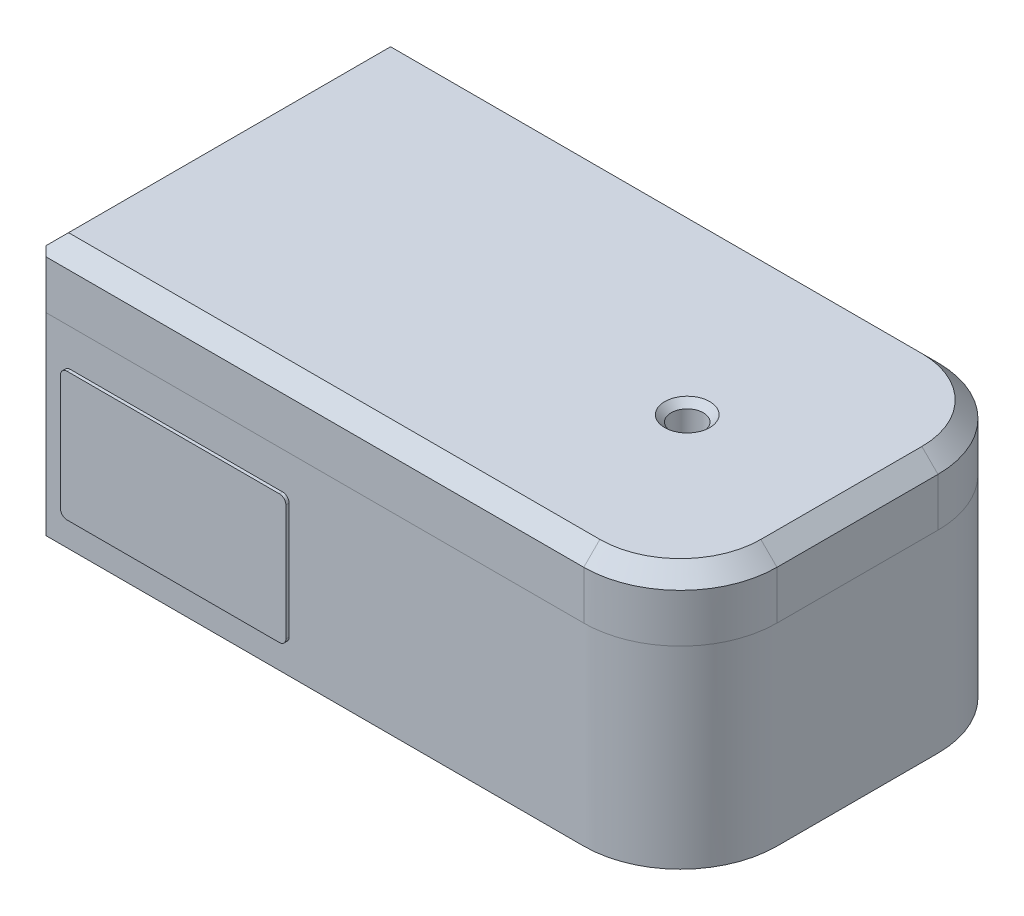
from build123d import *

# Parameters (mm, degrees)
SKETCH1_W           = 200
SKETCH1_H           = 110
BOSS_EXTRUDE1_DEPTH = 20
FILLET2_R           = 30
SKETCH2_R           = 5
CUT_EXTRUDE1_DEPTH  = 24
CHAMFER1_SIZE       = 5
BOSS_EXTRUDE2_DEPTH = 1
CUT_EXTRUDE2_DEPTH  = 5
CHAMFER2_SIZE       = 1
CHAMFER3_SIZE       = 2
CHAMFER4_SIZE       = 3


with BuildPart() as part:
    # Sketch1 → Boss-Extrude1 (new body)
    with BuildSketch(Plane(origin=(0, 0, 0), x_dir=(1, 0, 0), z_dir=(0, 1, 0))):
        with Locations((22.74566474, -0.63583815)):
            Rectangle(SKETCH1_W, SKETCH1_H)
    extrude(amount=BOSS_EXTRUDE1_DEPTH)

    # Fillet2
    fillet2_edges = [part.edges().sort_by_distance(p)[0] for p in [
        (122.74566474, 10, -54.36416185),
        (122.74566474, 10, 55.63583815),
    ]]
    fillet(fillet2_edges, radius=FILLET2_R)

    # Sketch4 → section 0 of loft1
    with BuildSketch(Plane(origin=(0, -60, 0), x_dir=(-1, 0, 0), z_dir=(0, -1, 0)), mode=Mode.PRIVATE) as loft1_s0:
        with BuildLine():
            Line((-122.74566474, 24.36416185), (-122.74566474, -25.63583815))
            ThreePointArc((-122.74566474, -25.63583815), (-113.958868175, -46.849041586), (-92.74566474, -55.63583815))
            Line((-92.74566474, -55.63583815), (77.25433526, -55.63583815))
            Line((77.25433526, -55.63583815), (77.25433526, 54.36416185))
            Line((77.25433526, 54.36416185), (-92.74566474, 54.36416185))
            ThreePointArc((-92.74566474, 54.36416185), (-113.958868175, 45.577365285), (-122.74566474, 24.36416185))
        make_face()
    # loft up to a face of the part (loft1)
    loft([loft1_s0.sketch, part.faces().sort_by_distance((21.078212912, 0, 0.63583815))[0]])

    # Sketch2 → Cut-Extrude1 (cut)
    with BuildSketch(Plane(origin=(0, 20, 0), x_dir=(1, 0, 0), z_dir=(0, 1, 0))):
        with Locations((72.74566474, -3.505923633)):
            Circle(SKETCH2_R)
    extrude(amount=-CUT_EXTRUDE1_DEPTH, mode=Mode.SUBTRACT)

    # Chamfer1
    chamfer1_edges = [part.edges().sort_by_distance(p)[0] for p in [
        (113.958868175, 20, 46.849041586),
        (7.74566474, 20, 55.63583815),
        (-77.25433526, 20, 0.63583815),
        (7.74566474, 20, -54.36416185),
        (113.958868175, 20, -45.577365285),
        (122.74566474, 20, 0.63583815),
    ]]
    chamfer(chamfer1_edges, length=CHAMFER1_SIZE)

    # Sketch5 → Boss-Extrude2 (add)
    with BuildSketch(Plane.XY.offset(55.63583815)):
        with BuildLine():
            ThreePointArc((-68.75433526, -13.5), (-68.168548822, -12.085786438), (-66.75433526, -11.5))
            Line((-66.75433526, -11.5), (-0.75433526, -11.5))
            ThreePointArc((-0.75433526, -11.5), (0.659878302, -12.085786438), (1.24566474, -13.5))
            Line((1.24566474, -13.5), (1.24566474, -49.5))
            ThreePointArc((1.24566474, -49.5), (0.659878302, -50.914213562), (-0.75433526, -51.5))
            Line((-0.75433526, -51.5), (-66.75433526, -51.5))
            ThreePointArc((-66.75433526, -51.5), (-68.168548822, -50.914213562), (-68.75433526, -49.5))
            Line((-68.75433526, -49.5), (-68.75433526, -13.5))
        make_face()
    extrude(amount=BOSS_EXTRUDE2_DEPTH)

    # Sketch6 → Cut-Extrude2 (cut)
    with BuildSketch(Plane.ZY.offset(77.25433526)):
        with BuildLine():
            Line((40.63583815, 5), (-39.36416185, 5))
            ThreePointArc((-39.36416185, 5), (-42.899695756, 3.535533906), (-44.36416185, 0))
            Line((-44.36416185, 0), (-44.36416185, -50))
            Line((-44.36416185, -50), (45.63583815, -50))
            Line((45.63583815, -50), (45.63583815, 0))
            ThreePointArc((45.63583815, 0), (44.171372056, 3.535533906), (40.63583815, 5))
        make_face()
    extrude(amount=-CUT_EXTRUDE2_DEPTH, mode=Mode.SUBTRACT)

    # Chamfer2
    chamfer2_edges = [part.edges().sort_by_distance(p)[0] for p in [
        (-77.25433526, 3.535533906, 44.171372056),
        (-77.25433526, 5, 0.63583815),
        (-77.25433526, 3.535533906, -42.899695756),
        (-77.25433526, -25, -44.36416185),
        (-77.25433526, -50, 0.63583815),
        (-77.25433526, -25, 45.63583815),
    ]]
    chamfer(chamfer2_edges, length=CHAMFER2_SIZE)

    # Chamfer3
    chamfer3_edges = [part.edges().sort_by_distance(p)[0] for p in [
        (67.74566474, 20, 3.505923633),
    ]]
    chamfer(chamfer3_edges, length=CHAMFER3_SIZE)

    # Chamfer4
    chamfer4_edges = [part.edges().sort_by_distance(p)[0] for p in [
        (-77.25433526, -22.5, 55.63583815),
        (-77.25433526, -22.5, 55.63583815),
        (-77.25433526, -22.5, -54.36416185),
        (-77.25433526, -22.5, -54.36416185),
    ]]
    chamfer(chamfer4_edges, length=CHAMFER4_SIZE)


solid = part.part
